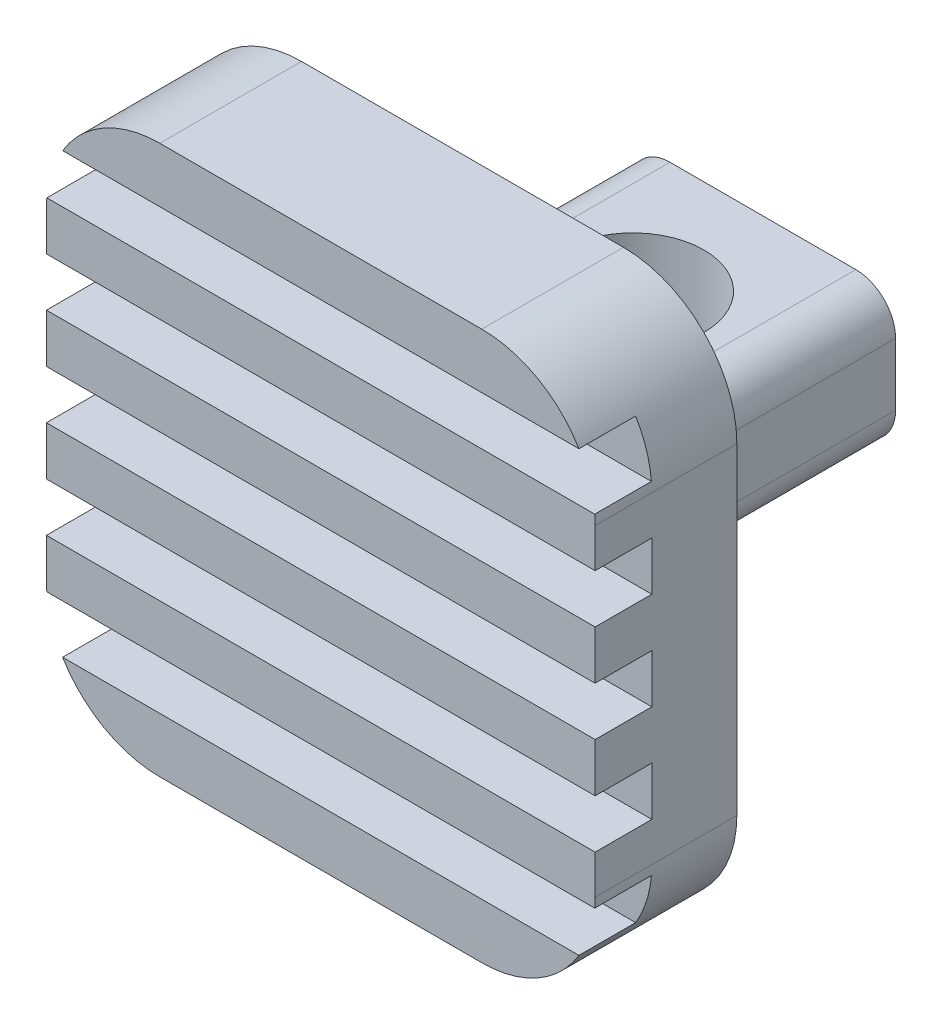
from build123d import *

# Parameters (mm, degrees)
SKETCH1_W               = 5.9436
SKETCH1_H               = 6.731
BOSS_EXTRUDE1_DEPTH     = 1.5875
SKETCH2_W               = 12.2936
SKETCH2_H               = 12.2936
BOSS_EXTRUDE2_DEPTH     = 3.175
SKETCH3_R               = 1.6002
CUT_EXTRUDE1_DEPTH      = 5.5593
CUT_EXTRUDE1_DEPTH_BACK = 8.7343
FILLET1_R               = 0.889
FILLET2_R               = 0.635
FILLET3_R               = 2.54
SKETCH4_W               = 1.27
SKETCH4_H               = 1.0922
CUT_EXTRUDE2_DEPTH      = 7.1468
LPATTERN1_COUNT         = 3
LPATTERN1_PITCH         = 2.1844
LPATTERN1_COL_COUNT     = 3
LPATTERN1_COL_PITCH     = 2.1844


with BuildPart() as part:
    # Sketch1 → Boss-Extrude1 (new body, symmetric)
    with BuildSketch(Plane(origin=(0, 0, 0), x_dir=(1, 0, 0), z_dir=(0, 1, 0))):
        Rectangle(SKETCH1_W, SKETCH1_H)
    extrude(amount=BOSS_EXTRUDE1_DEPTH, both=True)

    # Sketch2 → Boss-Extrude2 (add)
    with BuildSketch(Plane.XY.offset(3.3655)):
        Rectangle(SKETCH2_W, SKETCH2_H)
    extrude(amount=BOSS_EXTRUDE2_DEPTH)

    # Sketch3 → Cut-Extrude1 (cut, two sides)
    with BuildSketch(Plane(origin=(0, 1.5875, 0), x_dir=(1, 0, 0), z_dir=(0, 1, 0))) as cut_extrude1_sk:
        with Locations((0, 0.4445)):
            Circle(SKETCH3_R)
    extrude(amount=CUT_EXTRUDE1_DEPTH, mode=Mode.SUBTRACT)
    extrude(cut_extrude1_sk.sketch, amount=-CUT_EXTRUDE1_DEPTH_BACK, mode=Mode.SUBTRACT)

    # Fillet1
    fillet1_edges = [part.edges().sort_by_distance(p)[0] for p in [
        (-2.9718, 1.5875, 0),
        (2.9718, 1.5875, 0),
        (-2.9718, -1.5875, 0),
        (2.9718, -1.5875, 0),
    ]]
    fillet(fillet1_edges, radius=FILLET1_R)

    # Fillet2
    fillet2_edges = [part.edges().sort_by_distance(p)[0] for p in [
        (2.9718, 0, 3.3655),
        (0, -1.5875, 3.3655),
        (-2.9718, 0, 3.3655),
        (0, 1.5875, 3.3655),
        (2.711417928, -1.327117928, 3.3655),
        (-2.711417928, -1.327117928, 3.3655),
        (-2.711417928, 1.327117928, 3.3655),
        (2.711417928, 1.327117928, 3.3655),
    ]]
    fillet(fillet2_edges, radius=FILLET2_R)

    # Fillet3
    fillet3_edges = [part.edges().sort_by_distance(p)[0] for p in [
        (6.1468, -6.1468, 4.953),
        (6.1468, 6.1468, 4.953),
        (-6.1468, 6.1468, 4.953),
        (-6.1468, -6.1468, 4.953),
    ]]
    fillet(fillet3_edges, radius=FILLET3_R)

    # Sketch4 → Cut-Extrude2 (cut, symmetric)
    with BuildSketch(Plane(origin=(0, 0, 0), x_dir=(0, 0, -1), z_dir=(1, 0, 0))):
        with Locations((-5.9055, 0)):
            Rectangle(SKETCH4_W, SKETCH4_H)
    cut_extrude2 = extrude(amount=CUT_EXTRUDE2_DEPTH, both=True, mode=Mode.SUBTRACT)

    # LPattern1: Cut-Extrude2 ×3
    with Locations(*[(0, i * LPATTERN1_PITCH, 0) for i in range(1, LPATTERN1_COUNT)]):
        add(cut_extrude2, mode=Mode.SUBTRACT)

    # LPattern1 col: Cut-Extrude2 ×3
    with Locations(*[(0, -i * LPATTERN1_COL_PITCH, 0) for i in range(1, LPATTERN1_COL_COUNT)]):
        add(cut_extrude2, mode=Mode.SUBTRACT)


solid = part.part
